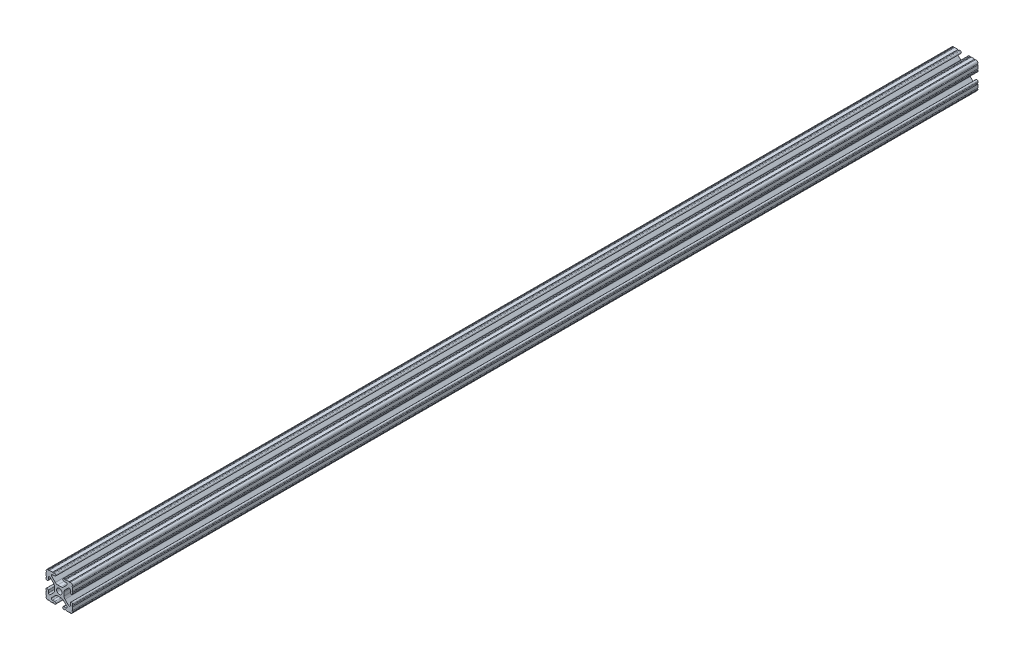
from build123d import *

# Parameters (mm, degrees)
SKETCH1_R           = 2.6035
BOSS_EXTRUDE1_DEPTH = 863.6


with BuildPart() as part:
    # Sketch1 → Boss-Extrude1 (new body)
    with BuildSketch(Plane(origin=(0, 0, -450.85), x_dir=(-1, 0, 0), z_dir=(0, 0, -1))):
        with BuildLine():
            Line((12.7, -9.5504), (12.7, -6.3330836))
            ThreePointArc((12.7, -6.3330836), (12.192, -5.8250836), (12.7, -5.3170836))
            Line((12.7, -5.3170836), (12.7, -4.3434))
            ThreePointArc((12.7, -4.3434), (11.5951, -3.2385), (10.4902, -4.3434))
            Line((10.4902, -4.3434), (10.4902, -6.474794456))
            ThreePointArc((10.4902, -6.474794456), (9.863006367, -7.413456061), (8.75577951, -7.193214945))
            Line((8.75577951, -7.193214945), (5.42573597, -3.863171405))
            ThreePointArc((5.42573597, -3.863171405), (4.737482484, -2.833127272), (4.4958, -1.618107374))
            Line((4.4958, -1.618107374), (4.4958, 1.618107374))
            ThreePointArc((4.4958, 1.618107374), (4.737482484, 2.833127272), (5.42573597, 3.863171405))
            Line((5.42573597, 3.863171405), (8.75577951, 7.193214945))
            ThreePointArc((8.75577951, 7.193214945), (9.863006367, 7.413456061), (10.4902, 6.474794456))
            Line((10.4902, 6.474794456), (10.4902, 4.343399971))
            ThreePointArc((10.4902, 4.343399971), (11.5951, 3.238499971), (12.7, 4.343399971))
            Line((12.7, 4.343399971), (12.7, 5.3170836))
            ThreePointArc((12.7, 5.3170836), (12.192, 5.8250836), (12.7, 6.3330836))
            Line((12.7, 6.3330836), (12.7, 9.5504))
            ThreePointArc((12.7, 9.5504), (12.192000006, 10.058323491), (12.699846982, 10.566399977))
            ThreePointArc((12.699846982, 10.566399977), (12.082522516, 12.082522516), (10.566399977, 12.699846982))
            ThreePointArc((10.566399977, 12.699846982), (10.058323491, 12.192000006), (9.5504, 12.7))
            Line((9.5504, 12.7), (6.3330836, 12.7))
            ThreePointArc((6.3330836, 12.7), (5.8250836, 12.192), (5.3170836, 12.7))
            Line((5.3170836, 12.7), (4.3434, 12.7))
            ThreePointArc((4.3434, 12.7), (3.2385, 11.5951), (4.3434, 10.4902))
            Line((4.3434, 10.4902), (6.474794456, 10.4902))
            ThreePointArc((6.474794456, 10.4902), (7.413456061, 9.863006367), (7.193214945, 8.75577951))
            Line((7.193214945, 8.75577951), (3.863171405, 5.42573597))
            ThreePointArc((3.863171405, 5.42573597), (2.833127272, 4.737482484), (1.618107374, 4.4958))
            Line((1.618107374, 4.4958), (-1.618107374, 4.4958))
            ThreePointArc((-1.618107374, 4.4958), (-2.833127272, 4.737482484), (-3.863171405, 5.42573597))
            Line((-3.863171405, 5.42573597), (-7.193214945, 8.75577951))
            ThreePointArc((-7.193214945, 8.75577951), (-7.413456061, 9.863006367), (-6.474794456, 10.4902))
            Line((-6.474794456, 10.4902), (-4.343399971, 10.4902))
            ThreePointArc((-4.343399971, 10.4902), (-3.238499971, 11.5951), (-4.343399971, 12.7))
            Line((-4.343399971, 12.7), (-5.3170836, 12.7))
            ThreePointArc((-5.3170836, 12.7), (-5.8250836, 12.192), (-6.3330836, 12.7))
            Line((-6.3330836, 12.7), (-9.5504, 12.7))
            ThreePointArc((-9.5504, 12.7), (-10.058323491, 12.192000006), (-10.566399977, 12.699846982))
            ThreePointArc((-10.566399977, 12.699846982), (-12.082522516, 12.082522516), (-12.699846982, 10.566399977))
            ThreePointArc((-12.699846982, 10.566399977), (-12.192000006, 10.058323491), (-12.7, 9.5504))
            Line((-12.7, 9.5504), (-12.7, 6.3330836))
            ThreePointArc((-12.7, 6.3330836), (-12.192, 5.8250836), (-12.7, 5.3170836))
            Line((-12.7, 5.3170836), (-12.7, 4.3434))
            ThreePointArc((-12.7, 4.3434), (-11.5951, 3.2385), (-10.4902, 4.3434))
            Line((-10.4902, 4.3434), (-10.4902, 6.474794456))
            ThreePointArc((-10.4902, 6.474794456), (-9.863006367, 7.413456061), (-8.75577951, 7.193214945))
            Line((-8.75577951, 7.193214945), (-5.42573597, 3.863171405))
            ThreePointArc((-5.42573597, 3.863171405), (-4.737482484, 2.833127272), (-4.4958, 1.618107374))
            Line((-4.4958, 1.618107374), (-4.4958, -1.618107374))
            ThreePointArc((-4.4958, -1.618107374), (-4.737482484, -2.833127272), (-5.42573597, -3.863171405))
            Line((-5.42573597, -3.863171405), (-8.75577951, -7.193214945))
            ThreePointArc((-8.75577951, -7.193214945), (-9.863006367, -7.413456061), (-10.4902, -6.474794456))
            Line((-10.4902, -6.474794456), (-10.4902, -4.343399971))
            ThreePointArc((-10.4902, -4.343399971), (-11.5951, -3.238499971), (-12.7, -4.343399971))
            Line((-12.7, -4.343399971), (-12.7, -5.3170836))
            ThreePointArc((-12.7, -5.3170836), (-12.192, -5.8250836), (-12.7, -6.3330836))
            Line((-12.7, -6.3330836), (-12.7, -9.5504))
            ThreePointArc((-12.7, -9.5504), (-12.192000006, -10.058323491), (-12.699846982, -10.566399977))
            ThreePointArc((-12.699846982, -10.566399977), (-12.082522516, -12.082522516), (-10.566399977, -12.699846982))
            ThreePointArc((-10.566399977, -12.699846982), (-10.058323491, -12.192000006), (-9.5504, -12.7))
            Line((-9.5504, -12.7), (-6.3330836, -12.7))
            ThreePointArc((-6.3330836, -12.7), (-5.8250836, -12.192), (-5.3170836, -12.7))
            Line((-5.3170836, -12.7), (-4.3434, -12.7))
            ThreePointArc((-4.3434, -12.7), (-3.2385, -11.5951), (-4.3434, -10.4902))
            Line((-4.3434, -10.4902), (-6.474794456, -10.4902))
            ThreePointArc((-6.474794456, -10.4902), (-7.413456061, -9.863006367), (-7.193214945, -8.75577951))
            Line((-7.193214945, -8.75577951), (-3.863171405, -5.42573597))
            ThreePointArc((-3.863171405, -5.42573597), (-2.833127272, -4.737482484), (-1.618107374, -4.4958))
            Line((-1.618107374, -4.4958), (1.618107374, -4.4958))
            ThreePointArc((1.618107374, -4.4958), (2.833127272, -4.737482484), (3.863171405, -5.42573597))
            Line((3.863171405, -5.42573597), (7.193214945, -8.75577951))
            ThreePointArc((7.193214945, -8.75577951), (7.413456061, -9.863006367), (6.474794456, -10.4902))
            Line((6.474794456, -10.4902), (4.343399971, -10.4902))
            ThreePointArc((4.343399971, -10.4902), (3.238499971, -11.5951), (4.343399971, -12.7))
            Line((4.343399971, -12.7), (5.3170836, -12.7))
            ThreePointArc((5.3170836, -12.7), (5.8250836, -12.192), (6.3330836, -12.7))
            Line((6.3330836, -12.7), (9.5504, -12.7))
            ThreePointArc((9.5504, -12.7), (10.058323491, -12.192000006), (10.566399977, -12.699846982))
            ThreePointArc((10.566399977, -12.699846982), (12.082522516, -12.082522516), (12.699846982, -10.566399977))
            ThreePointArc((12.699846982, -10.566399977), (12.192000006, -10.058323491), (12.7, -9.5504))
        make_face()
        Circle(SKETCH1_R, mode=Mode.SUBTRACT)
    extrude(amount=-BOSS_EXTRUDE1_DEPTH)


solid = part.part
